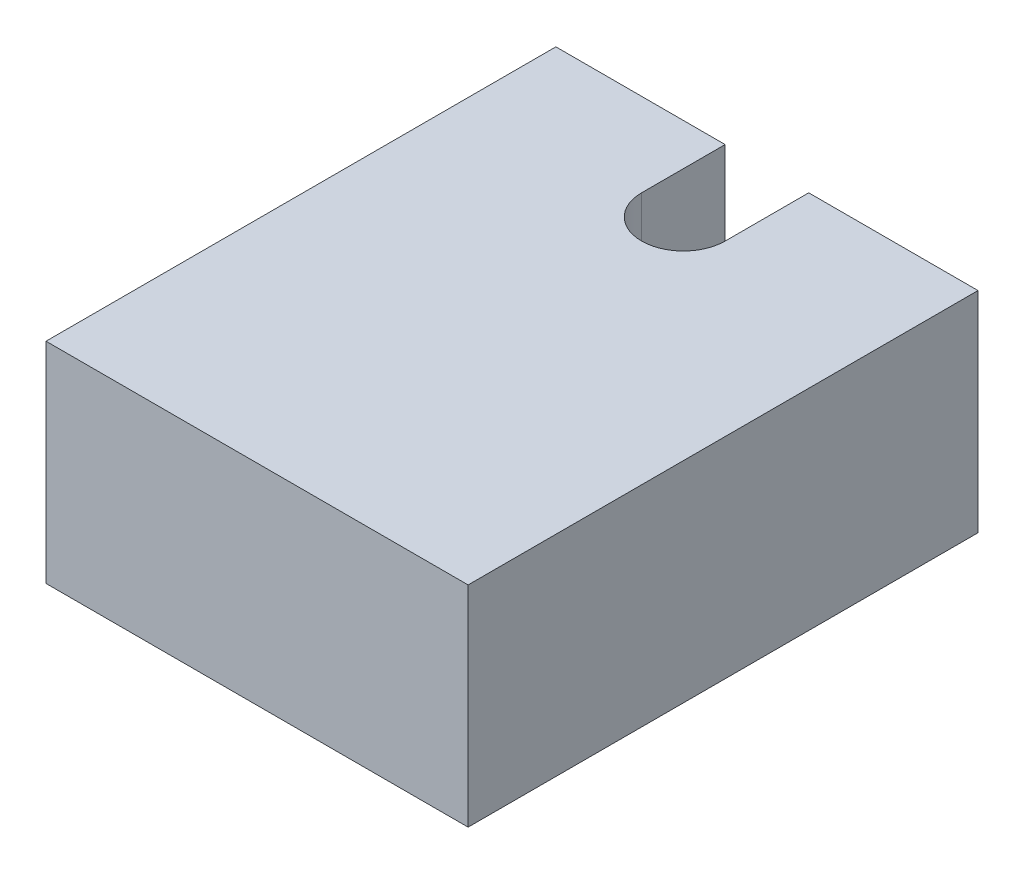
from build123d import *

# Parameters (mm, degrees)
EXTRUSION1_DEPTH = 2.51
ESQUISSE2_R      = 0.25
EXTRUSION2_DEPTH = 1


with BuildPart() as part:
    # Esquisse1 → Extrusion1 (new body)
    with BuildSketch(Plane(origin=(0, 0, 0), x_dir=(1, 0, 0), z_dir=(0, 1, 0))):
        with BuildLine():
            Line((3.025, 5.1), (3.025, 6.1))
            Line((3.025, 6.1), (5.05, 6.1))
            Line((5.05, 6.1), (5.05, 0))
            Line((5.05, 0), (0, 0))
            Line((0, 0), (0, 6.1))
            Line((0, 6.1), (2.025, 6.1))
            Line((2.025, 6.1), (2.025, 5.1))
            ThreePointArc((2.025, 5.1), (2.525, 4.6), (3.025, 5.1))
        make_face()
    extrude(amount=EXTRUSION1_DEPTH)

    # Esquisse2 → Extrusion2 (add)
    with BuildSketch(Plane(origin=(2.025, 0, 0), x_dir=(0, 0, -1), z_dir=(1, 0, 0))):
        with Locations(Location((5.6, 1.255, 0), (0, 0, 180))):  # turned: the seam where the file's is
            Circle(ESQUISSE2_R)
    extrude(amount=EXTRUSION2_DEPTH)


solid = part.part
